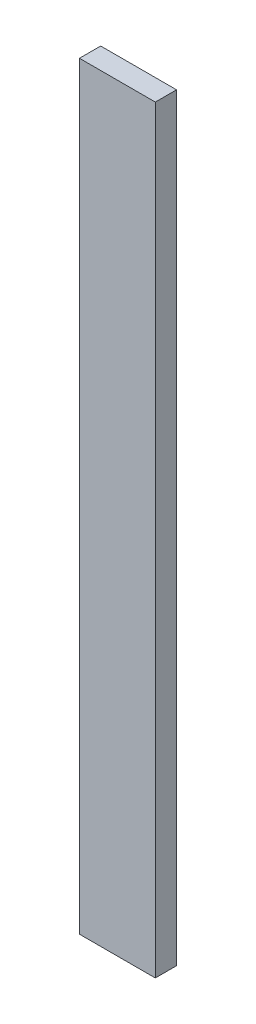
from build123d import *

# Parameters (mm, degrees)
SKETCH_1_W      = 20
SKETCH_1_H      = 5.597918572
EXTRUDE_1_DEPTH = 200


with BuildPart() as part:
    # Эскиз1 → Бобышка-Вытянуть1 (new body)
    with BuildSketch(Plane(origin=(0, 0, 0), x_dir=(1, 0, 0), z_dir=(0, 1, 0))):
        with Locations((10, 2.798959286)):
            Rectangle(SKETCH_1_W, SKETCH_1_H)
    extrude(amount=EXTRUDE_1_DEPTH)


solid = part.part
